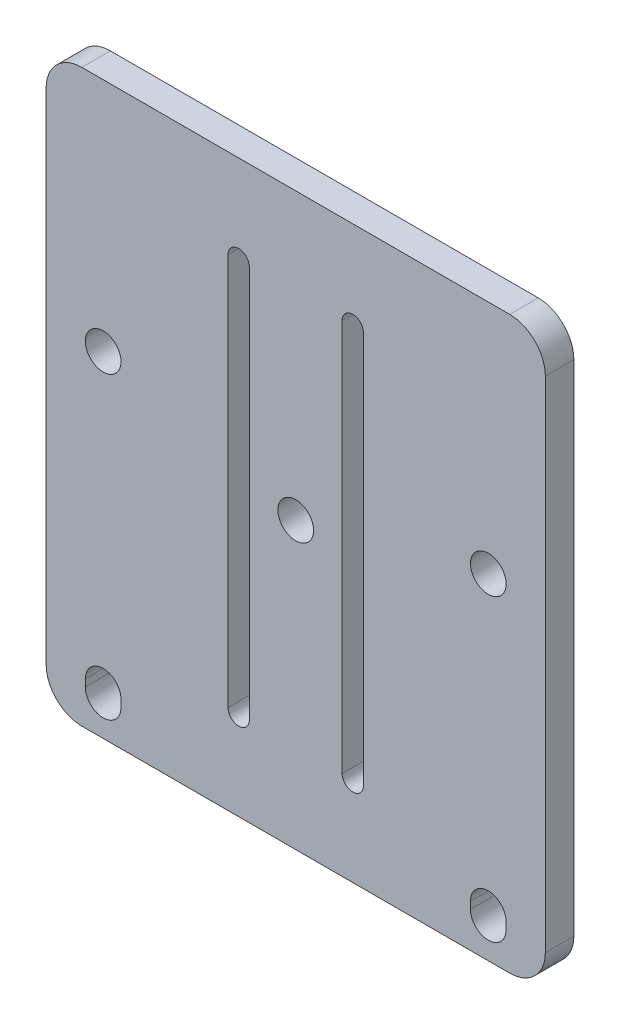
from build123d import *

# Parameters (mm, degrees)
SKETCH4_W           = 70
SKETCH4_H           = 80
SKETCH4_R           = 2.5
BOSS_EXTRUDE2_DEPTH = 4
FILLET1_R           = 5
SKETCH6_R           = 2.5
CUT_EXTRUDE1_DEPTH  = 5


with BuildPart() as part:
    # Sketch4 → Boss-Extrude2 (new body)
    with BuildSketch(Plane.XY):
        Rectangle(SKETCH4_W, SKETCH4_H)
        with Locations((-27, 7)):
            Circle(SKETCH4_R, mode=Mode.SUBTRACT)
        with Locations((27, 7)):
            Circle(SKETCH4_R, mode=Mode.SUBTRACT)
        with BuildLine():
            Line((-24.5, -34), (-24.5, -35))
            ThreePointArc((-24.5, -35), (-27, -37.5), (-29.5, -35))
            Line((-29.5, -35), (-29.5, -34))
            ThreePointArc((-29.5, -34), (-27, -31.5), (-24.5, -34))
        make_face(mode=Mode.SUBTRACT)
        with BuildLine():
            Line((24.5, -34), (24.5, -35))
            ThreePointArc((24.5, -35), (27, -37.5), (29.5, -35))
            Line((29.5, -35), (29.5, -34))
            ThreePointArc((29.5, -34), (27, -31.5), (24.5, -34))
        make_face(mode=Mode.SUBTRACT)
    extrude(amount=BOSS_EXTRUDE2_DEPTH)

    # Fillet1
    fillet1_edges = [part.edges().sort_by_distance(p)[0] for p in [
        (35, -40, 2),
        (-35, -40, 2),
        (-35, 40, 2),
        (35, 40, 2),
    ]]
    fillet(fillet1_edges, radius=FILLET1_R)

    # Sketch6 → Cut-Extrude1 (cut, through all)
    with BuildSketch(Plane.XY.offset(4)):
        Circle(SKETCH6_R)
        with BuildLine():
            Line((-6.5, 27.5), (-6.5, -27.5))
            ThreePointArc((-6.5, -27.5), (-8, -29), (-9.5, -27.5))
            Line((-9.5, -27.5), (-9.5, 27.5))
            ThreePointArc((-9.5, 27.5), (-8, 29), (-6.5, 27.5))
        make_face()
        with BuildLine():
            Line((6.5, 27.5), (6.5, -27.5))
            ThreePointArc((6.5, -27.5), (8, -29), (9.5, -27.5))
            Line((9.5, -27.5), (9.5, 27.5))
            ThreePointArc((9.5, 27.5), (8, 29), (6.5, 27.5))
        make_face()
    extrude(amount=-CUT_EXTRUDE1_DEPTH, mode=Mode.SUBTRACT)


solid = part.part
